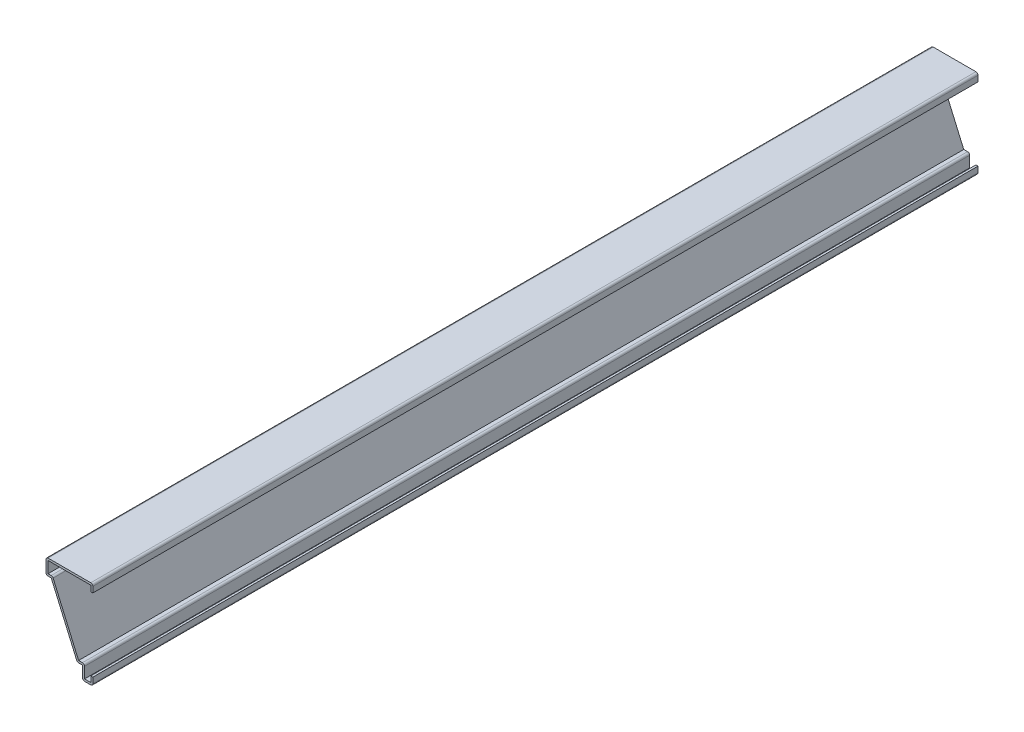
from build123d import *

# Parameters (mm, degrees)
EXTRUDE_THIN1_DEPTH = 539.75
FILLET1_R           = 1.27


with BuildPart() as part:
    # Sketch1 → Extrude-Thin1 (new body)
    with BuildSketch(Plane.XY):
        Polygon((0, 49.2125), (0, 53.975), (-28.575, 53.975), (-28.575, 44.45), (-25.4, 44.45), (-9.525, 7.9375), (-6.35, 7.9375), (-6.35, 0), (0, 0), (0, 4.7625), (-1.27, 4.7625), (-1.27, 1.27), (-5.08, 1.27), (-5.08, 9.2075), (-8.692328784, 9.2075), (-24.567328784, 45.72), (-27.305, 45.72), (-27.305, 52.705), (-1.27, 52.705), (-1.27, 49.2125), align=None)
    extrude(amount=-EXTRUDE_THIN1_DEPTH)

    # Fillet1
    fillet1_edges = [part.edges().sort_by_distance(p)[0] for p in [
        (0, 0, -269.875),
        (-6.35, 0, -269.875),
        (-9.525, 7.9375, -269.875),
        (-28.575, 44.45, -269.875),
        (-28.575, 53.975, -269.875),
        (0, 53.975, -269.875),
        (-24.567328784, 45.72, -269.875),
        (-5.08, 9.2075, -269.875),
    ]]
    fillet(fillet1_edges, radius=FILLET1_R)


solid = part.part
